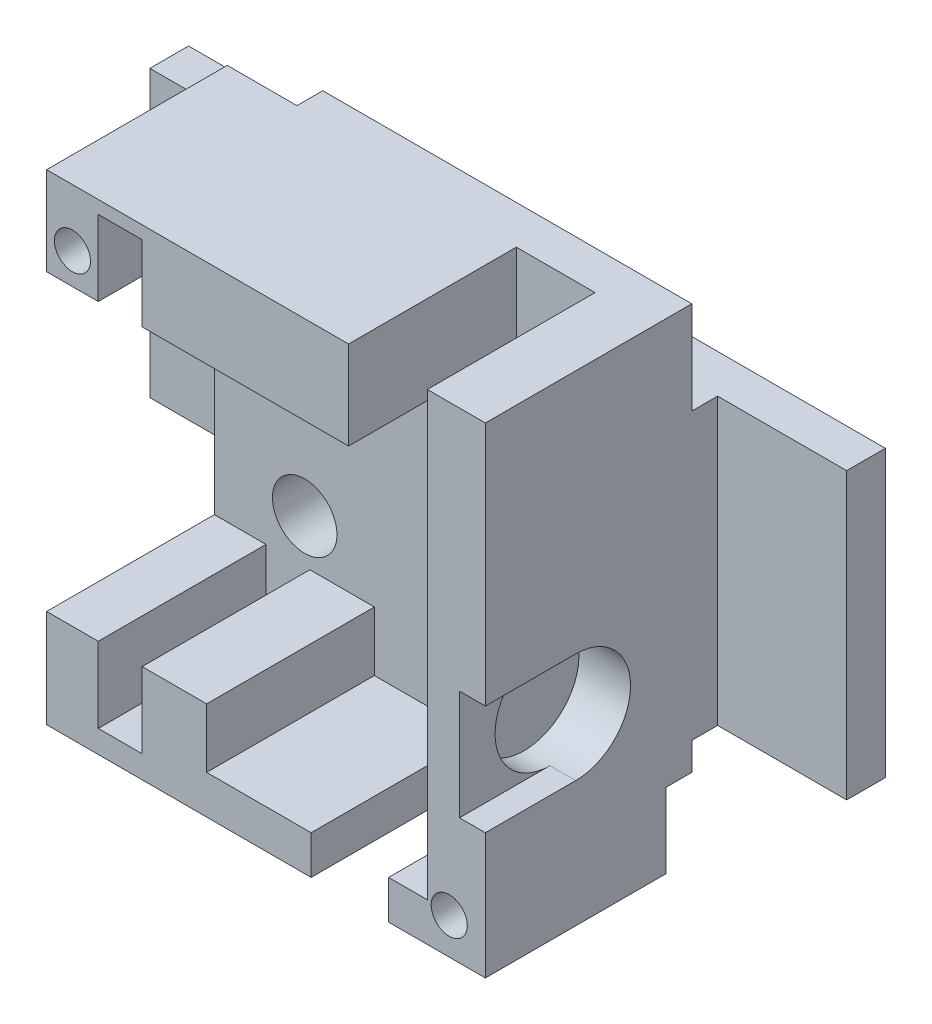
from build123d import *

# Parameters (mm, degrees)
SKETCH1_W                = 34
SKETCH1_H                = 38
BOSS_EXTRUDE1_DEPTH      = 16
SKETCH2_W                = 22.4
SKETCH2_H                = 22.8
SKETCH2_W_2              = 2.4
SKETCH2_H_2              = 4.85
CUT_EXTRUDE1_DEPTH       = 13
SKETCH3_W                = 10
SKETCH3_H                = 4.6
SKETCH3_W_2              = 3
CUT_EXTRUDE2_DEPTH       = 13
SKETCH4_R                = 1.4
CUT_EXTRUDE3_DEPTH       = 17
CUT_EXTRUDE5_DEPTH       = 2
SKETCH7_W                = 34
SKETCH7_H                = 1
CUT_EXTRUDE6_DEPTH       = 39
SKETCH9_W                = 8
SKETCH9_H                = 0.75
SKETCH9_W_2              = 5
SKETCH9_H_2              = 6.5
SKETCH9_W_3              = 3.6
SKETCH9_H_3              = 11.5
SKETCH9_W_4              = 17
SKETCH9_H_4              = 2
SKETCH9_W_5              = 3
SKETCH9_H_5              = 6.6
SKETCH9_W_6              = 5.4
CUT_EXTRUDE9_DEPTH       = 16
CUT_EXTRUDE10_DEPTH      = 13
CUT_EXTRUDE10_DEPTH_BACK = 2
SKETCH11_W               = 5
SKETCH11_H               = 4.5
CUT_EXTRUDE11_DEPTH      = 12
SKETCH12_W               = 1
SKETCH12_H               = 4.85
SKETCH12_H_2             = 22.8
CUT_EXTRUDE12_DEPTH      = 12
SKETCH14_R               = 4.25
CUT_EXTRUDE13_DEPTH      = 4
SKETCH17_W               = 3.4
SKETCH17_H               = 1
CUT_EXTRUDE16_DEPTH      = 12
SKETCH18_R               = 1.4
CUT_EXTRUDE17_DEPTH      = 12
BOSS_EXTRUDE2_DEPTH      = 16
SKETCH20_R               = 1.4
SKETCH20_W               = 3.4
SKETCH20_H               = 1
BOSS_EXTRUDE3_DEPTH      = 1
SKETCH21_W               = 5
SKETCH21_H               = 23.876697272
CUT_EXTRUDE18_DEPTH      = 13
BOSS_EXTRUDE4_DEPTH      = 10
SKETCH23_W               = 6.1
SKETCH23_H               = 6.85
CUT_EXTRUDE19_DEPTH      = 13
SKETCH26_W               = 1.2
SKETCH26_H               = 2
CUT_EXTRUDE21_DEPTH      = 2
SKETCH27_W               = 54
SKETCH27_H               = 22.100909166
SKETCH27_R               = 1.4
BOSS_EXTRUDE6_DEPTH      = 5
SKETCH28_W               = 10
SKETCH28_H               = 22.450454583
CUT_EXTRUDE22_DEPTH      = 5
SKETCH29_R               = 3.4
SKETCH29_R_2             = 1.4
CUT_EXTRUDE23_DEPTH      = 7
SKETCH30_R               = 2.5
SKETCH30_R_2             = 1.4
CUT_EXTRUDE24_DEPTH      = 3
SKETCH31_W               = 6
SKETCH31_H               = 3
CUT_EXTRUDE25_DEPTH      = 13
SKETCH32_W               = 7
SKETCH32_H               = 8.5
CUT_EXTRUDE26_DEPTH      = 2


with BuildPart() as part:
    # Sketch1 → Boss-Extrude1 (new body)
    with BuildSketch(Plane.XY):
        Rectangle(SKETCH1_W, SKETCH1_H)
    extrude(amount=BOSS_EXTRUDE1_DEPTH)

    # Sketch2 → Cut-Extrude1 (cut)
    with BuildSketch(Plane.XY.offset(16)):
        with Locations((-5.8, 0)):
            Rectangle(SKETCH2_W, SKETCH2_H)
        with Locations((-11.8, -13.825)):
            Rectangle(SKETCH2_W_2, SKETCH2_H_2)
        with Locations((-11.8, 13.825)):
            Rectangle(SKETCH2_W_2, SKETCH2_H_2)
    extrude(amount=-CUT_EXTRUDE1_DEPTH, mode=Mode.SUBTRACT)

    # Sketch3 → Cut-Extrude2 (cut)
    with BuildSketch(Plane.XY.offset(16)):
        Polygon((8.4, 19), (8.4, -11.4), (8.4, -16), (11.4, -16), (11.4, 19), align=None)
        with Locations((0.4, -13.7)):
            Rectangle(SKETCH3_W, SKETCH3_H)
        with Locations((6.9, -13.7)):
            Rectangle(SKETCH3_W_2, SKETCH3_H)
    extrude(amount=-CUT_EXTRUDE2_DEPTH, mode=Mode.SUBTRACT)

    # Sketch4 → Cut-Extrude3 (cut, through all)
    with BuildSketch(Plane.XY.offset(16)):
        with Locations((-15, 13.8)):
            Circle(SKETCH4_R)
        with Locations((14.2, -16.2)):
            Circle(SKETCH4_R)
    extrude(amount=-CUT_EXTRUDE3_DEPTH, mode=Mode.SUBTRACT)

    # Sketch5 → Cut-Extrude5 (cut)
    with BuildSketch(Plane(origin=(0, 0, 0), x_dir=(-1, 0, 0), z_dir=(0, 0, -1))):
        with BuildLine():
            Line((-14.2, -19), (-13.122967039, -19))
            ThreePointArc((-13.122967039, -19), (-11.727036304, -17.898367027), (-11.2, -16.2))
            ThreePointArc((-11.2, -16.2), (-12.078679656, -14.078679656), (-14.2, -13.2))
            Line((-14.2, -13.2), (-14.2, -14.8))
            ThreePointArc((-14.2, -14.8), (-13.210050506, -15.210050506), (-12.8, -16.2))
            ThreePointArc((-12.8, -16.2), (-13.210050506, -17.189949494), (-14.2, -17.6))
            Line((-14.2, -17.6), (-14.2, -19))
        make_face()
        with BuildLine():
            Line((-14.2, -14.8), (-14.2, -13.2))
            ThreePointArc((-14.2, -13.2), (-15.898367027, -13.727036304), (-17, -15.122967039))
            Line((-17, -15.122967039), (-17, -17.277032961))
            ThreePointArc((-17, -17.277032961), (-16.321320344, -18.321320344), (-15.277032961, -19))
            Line((-15.277032961, -19), (-14.2, -19))
            Line((-14.2, -19), (-14.2, -17.6))
            ThreePointArc((-14.2, -17.6), (-15.6, -16.2), (-14.2, -14.8))
        make_face()
        with BuildLine():
            Line((-17, -19), (-15.277032961, -19))
            ThreePointArc((-15.277032961, -19), (-16.321320344, -18.321320344), (-17, -17.277032961))
            Line((-17, -17.277032961), (-17, -19))
        make_face()
        with BuildLine():
            Line((-14.2, -13.2), (-17, -13.2))
            Line((-17, -13.2), (-17, -15.122967039))
            ThreePointArc((-17, -15.122967039), (-15.898367027, -13.727036304), (-14.2, -13.2))
        make_face()
        with BuildLine():
            Line((-17, -17.277032961), (-17, -15.122967039))
            ThreePointArc((-17, -15.122967039), (-17.2, -16.2), (-17, -17.277032961))
        make_face()
        with BuildLine():
            ThreePointArc((-14.2, -19.2), (-13.652277442, -19.149576241), (-13.122967039, -19))
            Line((-13.122967039, -19), (-14.2, -19))
            Line((-14.2, -19), (-14.2, -19.2))
        make_face()
        with BuildLine():
            ThreePointArc((-15.277032961, -19), (-14.747722558, -19.149576241), (-14.2, -19.2))
            Line((-14.2, -19.2), (-14.2, -19))
            Line((-14.2, -19), (-15.277032961, -19))
        make_face()
        with BuildLine():
            Line((-17, -19.2), (-14.2, -19.2))
            ThreePointArc((-14.2, -19.2), (-14.747722558, -19.149576241), (-15.277032961, -19))
            Line((-15.277032961, -19), (-17, -19))
            Line((-17, -19), (-17, -19.2))
        make_face()
        with BuildLine():
            ThreePointArc((-14.2, -19.2), (-13.652277442, -19.149576241), (-13.122967039, -19))
            Line((-13.122967039, -19), (-14.2, -19))
            Line((-14.2, -19), (-14.2, -19.2))
        make_face()
        with BuildLine():
            ThreePointArc((-15.277032961, -19), (-14.747722558, -19.149576241), (-14.2, -19.2))
            Line((-14.2, -19.2), (-14.2, -19))
            Line((-14.2, -19), (-15.277032961, -19))
        make_face()
        with BuildLine():
            ThreePointArc((17, 16.549545417), (18.029851482, 15.342724862), (18.4, 13.8))
            Line((18.4, 13.8), (18.4, 19))
            Line((18.4, 19), (17, 19))
            Line((17, 19), (17, 16.549545417))
        make_face()
        with BuildLine():
            ThreePointArc((11.6, 13.8), (13.457275138, 16.829851482), (17, 16.549545417))
            Line((17, 16.549545417), (17, 19))
            Line((17, 19), (11.6, 19))
            Line((11.6, 19), (11.6, 13.8))
        make_face()
        with BuildLine():
            Line((17, 11.050454583), (17, 13.8))
            Line((17, 13.8), (16.4, 13.8))
            ThreePointArc((16.4, 13.8), (15, 12.4), (13.6, 13.8))
            Line((13.6, 13.8), (11.6, 13.8))
            ThreePointArc((11.6, 13.8), (13.457275138, 10.770148518), (17, 11.050454583))
        make_face()
        with BuildLine():
            Line((16.4, 13.8), (17, 13.8))
            Line((17, 13.8), (17, 16.549545417))
            ThreePointArc((17, 16.549545417), (13.457275138, 16.829851482), (11.6, 13.8))
            Line((11.6, 13.8), (13.6, 13.8))
            ThreePointArc((13.6, 13.8), (15, 15.2), (16.4, 13.8))
        make_face()
        with BuildLine():
            ThreePointArc((17, 11.050454583), (18.029851482, 12.257275138), (18.4, 13.8))
            Line((18.4, 13.8), (17, 13.8))
            Line((17, 13.8), (17, 11.050454583))
        make_face()
        with BuildLine():
            Line((17, 13.8), (18.4, 13.8))
            ThreePointArc((18.4, 13.8), (18.029851482, 15.342724862), (17, 16.549545417))
            Line((17, 16.549545417), (17, 13.8))
        make_face()
        with BuildLine():
            ThreePointArc((17, 11.050454583), (18.029851482, 12.257275138), (18.4, 13.8))
            Line((18.4, 13.8), (17, 13.8))
            Line((17, 13.8), (17, 11.050454583))
        make_face()
        with BuildLine():
            Line((17, 13.8), (18.4, 13.8))
            ThreePointArc((18.4, 13.8), (18.029851482, 15.342724862), (17, 16.549545417))
            Line((17, 16.549545417), (17, 13.8))
        make_face()
        with BuildLine():
            Line((17, 11.050454583), (17, 13.8))
            Line((17, 13.8), (16.4, 13.8))
            ThreePointArc((16.4, 13.8), (15, 12.4), (13.6, 13.8))
            Line((13.6, 13.8), (11.6, 13.8))
            ThreePointArc((11.6, 13.8), (13.457275138, 10.770148518), (17, 11.050454583))
        make_face()
        with BuildLine():
            Line((16.4, 13.8), (17, 13.8))
            Line((17, 13.8), (17, 16.549545417))
            ThreePointArc((17, 16.549545417), (13.457275138, 16.829851482), (11.6, 13.8))
            Line((11.6, 13.8), (13.6, 13.8))
            ThreePointArc((13.6, 13.8), (15, 15.2), (16.4, 13.8))
        make_face()
        with BuildLine():
            Line((-13.122967039, -19), (-10.2, -19))
            Line((-10.2, -19), (-10.2, -13.2))
            Line((-10.2, -13.2), (-14.2, -13.2))
            ThreePointArc((-14.2, -13.2), (-12.078679656, -14.078679656), (-11.2, -16.2))
            ThreePointArc((-11.2, -16.2), (-11.727036304, -17.898367027), (-13.122967039, -19))
        make_face()
    extrude(amount=-CUT_EXTRUDE5_DEPTH, mode=Mode.SUBTRACT)

    # Sketch7 → Cut-Extrude6 (cut, through all)
    with BuildSketch(Plane(origin=(0, 19, 0), x_dir=(1, 0, 0), z_dir=(0, 1, 0))):
        with Locations((0, -15.5)):
            Rectangle(SKETCH7_W, SKETCH7_H)
    extrude(amount=-CUT_EXTRUDE6_DEPTH, mode=Mode.SUBTRACT)

    # Sketch9 → Cut-Extrude9 (cut, through all)
    with BuildSketch(Plane.XY.offset(15)):
        Polygon((8.4, 19), (-9, 19), (-9, 18.25), (-9, 12.5), (8.4, 12.5), align=None)
        with Locations((-13, 18.625)):
            Rectangle(SKETCH9_W, SKETCH9_H)
        with Locations((10.9, 15.75)):
            Rectangle(SKETCH9_W_2, SKETCH9_H_2)
        with Locations((15.2, 15.75)):
            Rectangle(SKETCH9_W_3, SKETCH9_H_2)
        with Locations((15.2, 6.75)):
            Rectangle(SKETCH9_W_3, SKETCH9_H_3)
        with Locations((2.9, -18)):
            Rectangle(SKETCH9_W_4, SKETCH9_H_4)
        with Locations((-7.1, -15.7)):
            Rectangle(SKETCH9_W_5, SKETCH9_H_5)
        with Locations((-11.3, -18.625)):
            Rectangle(SKETCH9_W_6, SKETCH9_H)
        with Locations((-15.5, -15.7)):
            Rectangle(SKETCH9_W_5, SKETCH9_H_5)
    extrude(amount=-CUT_EXTRUDE9_DEPTH, mode=Mode.SUBTRACT)

    # Sketch10 → Cut-Extrude10 (cut, two sides)
    with BuildSketch(Plane.XY.offset(3)) as cut_extrude10_sk:
        with BuildLine():
            Line((-10, 5.5), (-10, 8))
            Line((-10, 8), (-7.5, 8))
            ThreePointArc((-7.5, 8), (-11.767766953, 9.767766953), (-10, 5.5))
        make_face()
        with BuildLine():
            Line((-7.5, 8), (-10, 8))
            Line((-10, 8), (-10, 5.5))
            ThreePointArc((-10, 5.5), (-8.232233047, 6.232233047), (-7.5, 8))
        make_face()
        with BuildLine():
            Line((-10, 5.5), (-10, 8))
            Line((-10, 8), (-7.5, 8))
            ThreePointArc((-7.5, 8), (-11.767766953, 9.767766953), (-10, 5.5))
        make_face()
        with BuildLine():
            Line((-7.5, 8), (-10, 8))
            Line((-10, 8), (-10, 5.5))
            ThreePointArc((-10, 5.5), (-8.232233047, 6.232233047), (-7.5, 8))
        make_face()
        with BuildLine():
            Line((10, 8), (8.4, 8))
            Line((8.4, 8), (8.4, 6.079062729))
            ThreePointArc((8.4, 6.079062729), (9.149218941, 5.649218941), (10, 5.5))
            Line((10, 5.5), (10, 8))
        make_face()
        with BuildLine():
            Line((8.4, 9.920937271), (8.4, 8))
            Line((8.4, 8), (10, 8))
            Line((10, 8), (10, 5.5))
            ThreePointArc((10, 5.5), (10.732093302, 5.609594303), (11.4, 5.928768482))
            Line((11.4, 5.928768482), (11.4, 10.071231518))
            ThreePointArc((11.4, 10.071231518), (9.874911671, 10.496868621), (8.4, 9.920937271))
        make_face()
        with BuildLine():
            ThreePointArc((12.5, 8), (12.207940217, 9.17260394), (11.4, 10.071231518))
            Line((11.4, 10.071231518), (11.4, 5.928768482))
            ThreePointArc((11.4, 5.928768482), (12.207940217, 6.82739606), (12.5, 8))
        make_face()
        with BuildLine():
            ThreePointArc((8.4, 9.920937271), (7.736153715, 9.060660172), (7.5, 8))
            Line((7.5, 8), (8.4, 8))
            Line((8.4, 8), (8.4, 9.920937271))
        make_face()
        with BuildLine():
            Line((8.4, 8), (7.5, 8))
            ThreePointArc((7.5, 8), (7.736153715, 6.939339828), (8.4, 6.079062729))
            Line((8.4, 6.079062729), (8.4, 8))
        make_face()
        with BuildLine():
            ThreePointArc((8.4, 9.920937271), (7.736153715, 9.060660172), (7.5, 8))
            Line((7.5, 8), (8.4, 8))
            Line((8.4, 8), (8.4, 9.920937271))
        make_face()
        with BuildLine():
            Line((8.4, 8), (7.5, 8))
            ThreePointArc((7.5, 8), (7.736153715, 6.939339828), (8.4, 6.079062729))
            Line((8.4, 6.079062729), (8.4, 8))
        make_face()
        with BuildLine():
            ThreePointArc((-7.5, -8), (-8.232233047, -6.232233047), (-10, -5.5))
            Line((-10, -5.5), (-10, -8))
            Line((-10, -8), (-7.5, -8))
        make_face()
        with BuildLine():
            Line((-10, -8), (-10, -5.5))
            ThreePointArc((-10, -5.5), (-11.767766953, -9.767766953), (-7.5, -8))
            Line((-7.5, -8), (-10, -8))
        make_face()
        with BuildLine():
            ThreePointArc((-7.5, -8), (-8.232233047, -6.232233047), (-10, -5.5))
            Line((-10, -5.5), (-10, -8))
            Line((-10, -8), (-7.5, -8))
        make_face()
        with BuildLine():
            Line((-10, -8), (-10, -5.5))
            ThreePointArc((-10, -5.5), (-11.767766953, -9.767766953), (-7.5, -8))
            Line((-7.5, -8), (-10, -8))
        make_face()
        with BuildLine():
            ThreePointArc((11.4, -5.928768482), (10.732093302, -5.609594303), (10, -5.5))
            Line((10, -5.5), (10, -8))
            Line((10, -8), (8.4, -8))
            Line((8.4, -8), (8.4, -9.920937271))
            ThreePointArc((8.4, -9.920937271), (9.874911671, -10.496868621), (11.4, -10.071231518))
            Line((11.4, -10.071231518), (11.4, -5.928768482))
        make_face()
        with BuildLine():
            ThreePointArc((12.5, -8), (12.207940217, -6.82739606), (11.4, -5.928768482))
            Line((11.4, -5.928768482), (11.4, -10.071231518))
            ThreePointArc((11.4, -10.071231518), (12.207940217, -9.17260394), (12.5, -8))
        make_face()
        with BuildLine():
            ThreePointArc((10, -5.5), (9.149218941, -5.649218941), (8.4, -6.079062729))
            Line((8.4, -6.079062729), (8.4, -8))
            Line((8.4, -8), (10, -8))
            Line((10, -8), (10, -5.5))
        make_face()
        with BuildLine():
            Line((8.4, -8), (8.4, -6.079062729))
            ThreePointArc((8.4, -6.079062729), (7.736153715, -6.939339828), (7.5, -8))
            Line((7.5, -8), (8.4, -8))
        make_face()
        with BuildLine():
            Line((8.4, -8), (7.5, -8))
            ThreePointArc((7.5, -8), (7.736153715, -9.060660172), (8.4, -9.920937271))
            Line((8.4, -9.920937271), (8.4, -8))
        make_face()
        with BuildLine():
            Line((8.4, -8), (8.4, -6.079062729))
            ThreePointArc((8.4, -6.079062729), (7.736153715, -6.939339828), (7.5, -8))
            Line((7.5, -8), (8.4, -8))
        make_face()
        with BuildLine():
            Line((8.4, -8), (7.5, -8))
            ThreePointArc((7.5, -8), (7.736153715, -9.060660172), (8.4, -9.920937271))
            Line((8.4, -9.920937271), (8.4, -8))
        make_face()
    extrude(amount=CUT_EXTRUDE10_DEPTH, mode=Mode.SUBTRACT)
    extrude(cut_extrude10_sk.sketch, amount=-CUT_EXTRUDE10_DEPTH_BACK, mode=Mode.SUBTRACT)

    # Sketch11 → Cut-Extrude11 (cut)
    with BuildSketch(Plane.XY.offset(15)):
        Polygon((12.5, -8), (7.5, -8), (7.5, -11.4), (11.4, -11.4), (11.4, -16), (12.5, -16), (12.5, -11.4), align=None)
        with Locations((10, 10.25)):
            Rectangle(SKETCH11_W, SKETCH11_H)
    extrude(amount=-CUT_EXTRUDE11_DEPTH, mode=Mode.SUBTRACT)

    # Sketch12 → Cut-Extrude12 (cut)
    with BuildSketch(Plane.XY.offset(15)):
        with Locations((-10.1, 13.825)):
            Rectangle(SKETCH12_W, SKETCH12_H)
        with Locations((-10.1, -13.825)):
            Rectangle(SKETCH12_W, SKETCH12_H)
        with Locations((5.9, 0)):
            Rectangle(SKETCH12_W, SKETCH12_H_2)
    extrude(amount=-CUT_EXTRUDE12_DEPTH, mode=Mode.SUBTRACT)

    # Sketch14 → Cut-Extrude13 (cut)
    with BuildSketch(Plane(origin=(17, 0, 0), x_dir=(0, 0, -1), z_dir=(1, 0, 0))):
        with Locations((-9, -5)):
            Circle(SKETCH14_R)
    extrude(amount=-CUT_EXTRUDE13_DEPTH, mode=Mode.SUBTRACT)

    # Sketch17 → Cut-Extrude16 (cut)
    with BuildSketch(Plane.XY.offset(15)):
        with Locations((-11.3, 16.75)):
            Rectangle(SKETCH17_W, SKETCH17_H)
        with Locations((-11.3, -16.75)):
            Rectangle(SKETCH17_W, SKETCH17_H)
    extrude(amount=-CUT_EXTRUDE16_DEPTH, mode=Mode.SUBTRACT)

    # Sketch18 → Cut-Extrude17 (cut)
    with BuildSketch(Plane.XY.offset(1)):
        with Locations((-10, 8)):
            Circle(SKETCH18_R)
        with Locations((10, 8)):
            Circle(SKETCH18_R)
        with Locations((-10, -8)):
            Circle(SKETCH18_R)
        with Locations((10, -8)):
            Circle(SKETCH18_R)
    extrude(amount=-CUT_EXTRUDE17_DEPTH, mode=Mode.SUBTRACT)

    # Sketch19 → Boss-Extrude2 (add)
    with BuildSketch(Plane.XY):
        Polygon((17, 18.25), (-9, 18.25), (-9, 12.476697272), (13.4, 12.476697272), (13.4, 1), (17, 1), align=None)
        Polygon((-14, -12.4), (-17, -12.4), (-17, -19), (11.4, -19), (11.4, -17), (-5.6, -17), (-5.6, -12.4), (-8.6, -12.4), (-8.6, -18.25), (-14, -18.25), align=None)
    extrude(amount=BOSS_EXTRUDE2_DEPTH)

    # Sketch20 → Boss-Extrude3 (add)
    with BuildSketch(Plane.XY.offset(15)):
        Polygon((-13, 18.25), (-17, 18.25), (-17, 11.4), (-13, 11.4), (-13, 17.25), align=None)
        with Locations((-15, 13.8)):
            Circle(SKETCH20_R, mode=Mode.SUBTRACT)
        with Locations((-11.3, 17.75)):
            Rectangle(SKETCH20_W, SKETCH20_H)
        Polygon((-9, 18.25), (-9.6, 18.25), (-9.6, 17.25), (-9.6, 11.4), (-9, 11.4), (-9, 12.476697272), align=None)
        Polygon((7.5, 12.476697272), (-9, 12.476697272), (-9, 11.4), (6.4, 11.4), (7.5, 11.4), align=None)
        Polygon((7.5, 11.4), (6.4, 11.4), (6.4, -11.4), (7.5, -11.4), (7.5, -8), (7.5, 8), align=None)
        Polygon((-13, -11.4), (-17, -11.4), (-17, -12.4), (-14, -12.4), (-14, -18.25), (-8.6, -18.25), (-8.6, -12.4), (-5.6, -12.4), (-5.6, -17), (11.4, -17), (11.4, -19), (13.4, -19), (17, -19), (17, 1), (13.4, 1), (13.4, 12.476697272), (12.5, 12.476697272), (12.5, -16), (-4.6, -16), (-4.6, -11.4), (-9.6, -11.4), (-9.6, -17.25), (-13, -17.25), align=None)
        with Locations((14.2, -16.2)):
            Circle(SKETCH20_R, mode=Mode.SUBTRACT)
    extrude(amount=BOSS_EXTRUDE3_DEPTH)

    # Sketch21 → Cut-Extrude18 (cut)
    with BuildSketch(Plane.XY.offset(16)):
        with Locations((10, 0.538348636)):
            Rectangle(SKETCH21_W, SKETCH21_H)
        Polygon((7.5, -11.4), (7.5, 12.476697272), (6.4, 12.476697272), (6.4, 11.4), (6.4, -11.4), align=None)
    extrude(amount=-CUT_EXTRUDE18_DEPTH, mode=Mode.SUBTRACT)

    # Sketch22 → Boss-Extrude4 (add)
    with BuildSketch(Plane.ZY.offset(17)):
        Polygon((2, 11.050454583), (0, 11.050454583), (0, -11.4), (3, -11.4), (3, 11.050454583), align=None)
    boss_extrude4 = extrude(amount=BOSS_EXTRUDE4_DEPTH)

    # Mirror1: Boss-Extrude4 across plane
    add(boss_extrude4.mirror(Plane(origin=(0, 0, 0), x_dir=(0, 0, 1), z_dir=(1, 0, 0))))

    # Sketch23 → Cut-Extrude19 (cut)
    with BuildSketch(Plane.XY.offset(16)):
        with Locations((9.45, 14.825)):
            Rectangle(SKETCH23_W, SKETCH23_H)
    extrude(amount=-CUT_EXTRUDE19_DEPTH, mode=Mode.SUBTRACT)

    # Sketch26 → Cut-Extrude21 (cut)
    with BuildSketch(Plane(origin=(0, 0, 0), x_dir=(-1, 0, 0), z_dir=(0, 0, -1))):
        with Locations((-10.8, -18)):
            Rectangle(SKETCH26_W, SKETCH26_H)
    extrude(amount=-CUT_EXTRUDE21_DEPTH, mode=Mode.SUBTRACT)

    # Sketch27 → Boss-Extrude6 (add)
    with BuildSketch(Plane(origin=(0, 0, 0), x_dir=(-1, 0, 0), z_dir=(0, 0, -1))):
        Rectangle(SKETCH27_W, SKETCH27_H)
        with Locations((-10, 8)):
            Circle(SKETCH27_R, mode=Mode.SUBTRACT)
        with Locations((-10, -8)):
            Circle(SKETCH27_R, mode=Mode.SUBTRACT)
        with Locations((10, -8)):
            Circle(SKETCH27_R, mode=Mode.SUBTRACT)
        with Locations((10, 8)):
            Circle(SKETCH27_R, mode=Mode.SUBTRACT)
    extrude(amount=BOSS_EXTRUDE6_DEPTH)

    # Sketch28 → Cut-Extrude22 (cut)
    with BuildSketch(Plane.XY.offset(3)):
        with Locations((-22, -0.174772708)):
            Rectangle(SKETCH28_W, SKETCH28_H)
        with Locations((22, -0.174772708)):
            Rectangle(SKETCH28_W, SKETCH28_H)
    extrude(amount=-CUT_EXTRUDE22_DEPTH, mode=Mode.SUBTRACT)

    # Sketch29 → Cut-Extrude23 (cut)
    with BuildSketch(Plane(origin=(0, 0, 2), x_dir=(-1, 0, 0), z_dir=(0, 0, -1))):
        with Locations((15, 13.8)):
            Circle(SKETCH29_R)
        with Locations((15, 13.8)):
            Circle(SKETCH29_R_2, mode=Mode.SUBTRACT)
    extrude(amount=CUT_EXTRUDE23_DEPTH, mode=Mode.SUBTRACT)

    # Sketch30 → Cut-Extrude24 (cut)
    with BuildSketch(Plane.XY.offset(1)):
        with Locations((-10, 8)):
            Circle(SKETCH30_R)
        with Locations((-10, 8)):
            Circle(SKETCH30_R_2, mode=Mode.SUBTRACT)
        with Locations((-10, -8)):
            Circle(SKETCH30_R)
        with Locations((-10, -8)):
            Circle(SKETCH30_R_2, mode=Mode.SUBTRACT)
        with Locations((10, -8)):
            Circle(SKETCH30_R)
        with Locations((10, -8)):
            Circle(SKETCH30_R_2, mode=Mode.SUBTRACT)
        with Locations((10, 8)):
            Circle(SKETCH30_R)
        with Locations((10, 8)):
            Circle(SKETCH30_R_2, mode=Mode.SUBTRACT)
    extrude(amount=-CUT_EXTRUDE24_DEPTH, mode=Mode.SUBTRACT)

    # Sketch31 → Cut-Extrude25 (cut)
    with BuildSketch(Plane.XY.offset(16)):
        with Locations((6.5, -17.5)):
            Rectangle(SKETCH31_W, SKETCH31_H)
    extrude(amount=-CUT_EXTRUDE25_DEPTH, mode=Mode.SUBTRACT)

    # Sketch32 → Cut-Extrude26 (cut)
    with BuildSketch(Plane(origin=(17, 0, 0), x_dir=(0, 0, -1), z_dir=(1, 0, 0))):
        with Locations((-12.5, -5)):
            Rectangle(SKETCH32_W, SKETCH32_H)
    extrude(amount=-CUT_EXTRUDE26_DEPTH, mode=Mode.SUBTRACT)


solid = part.part
